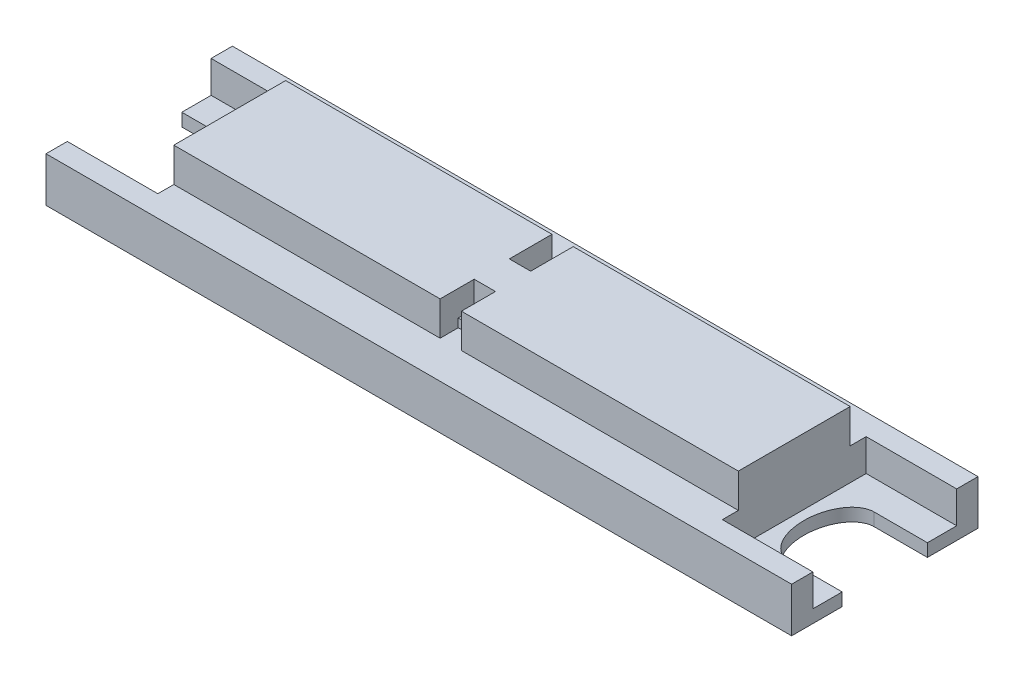
from build123d import *

# Parameters (mm, degrees)
CROQUIS1_W                   = 70
CROQUIS1_H                   = 17.5
SALIENTE_EXTRUIR1_DEPTH      = 4.2
CROQUIS2_W                   = 8.5
CROQUIS2_H                   = 13.5
CORTAR_EXTRUIR1_DEPTH        = 3
CORTAR_EXTRUIR2_DEPTH        = 2.2
SALIENTE_EXTRUIR2_DEPTH      = 3.2
CROQUIS5_R                   = 6.5
CORTAR_EXTRUIR3_DEPTH        = 4
CROQUIS6_W                   = 3.5
CROQUIS6_H                   = 6.5
CORTAR_EXTRUIR4_DEPTH        = 1
CROQUIS7_W                   = 14
CROQUIS7_H                   = 2
CORTAR_EXTRUIR5_DEPTH        = 1
CORTAR_EXTRUIR6_DEPTH        = 4
CROQUIS9_W                   = 3.489148649
CROQUIS9_H                   = 7.1
SALIENTE_EXTRUIR3_DEPTH      = 2
SALIENTE_EXTRUIR3_DEPTH_BACK = 1


with BuildPart() as part:
    # Croquis1 → Saliente-Extruir1 (new body)
    with BuildSketch(Plane(origin=(0, 0, 0), x_dir=(1, 0, 0), z_dir=(0, 1, 0))):
        with Locations((2.27027027, -4.304054054)):
            Rectangle(CROQUIS1_W, CROQUIS1_H)
    extrude(amount=SALIENTE_EXTRUIR1_DEPTH)

    # Croquis2 → Cortar-Extruir1 (cut)
    with BuildSketch(Plane(origin=(0, 4.2, 0), x_dir=(1, 0, 0), z_dir=(0, 1, 0))):
        with Locations((33.02027027, -4.304054054)):
            Rectangle(CROQUIS2_W, CROQUIS2_H)
        with Locations((-28.47972973, -4.304054054)):
            Rectangle(CROQUIS2_W, CROQUIS2_H)
    extrude(amount=-CORTAR_EXTRUIR1_DEPTH, mode=Mode.SUBTRACT)

    # Croquis3 → Cortar-Extruir2 (cut, through all)
    with BuildSketch(Plane(origin=(0, 1.2, 0), x_dir=(1, 0, 0), z_dir=(0, 1, 0))):
        with BuildLine():
            Line((37.27027027, -0.304054054), (32.27027027, -0.304054054))
            add(Edge.make_bspline(
                [(32.27027027, -0.304054054), (28.823561714, -0.304054054), (29.77027027, -5.402735351)],
                knots=[0, 0, 0, 1.84904315, 1.84904315, 1.84904315], degree=2, weights=[1, 0.602216604, 1]))
            add(Edge.make_bspline(
                [(29.77027027, -5.402735351), (30.308978827, -8.304054054), (32.27027027, -8.304054054)],
                knots=[4.990635803, 4.990635803, 4.990635803, 6.283185307, 6.283185307, 6.283185307], degree=2, weights=[1, 0.798332739, 1]))
            Line((32.27027027, -8.304054054), (37.27027027, -8.304054054))
            Line((37.27027027, -8.304054054), (37.27027027, -0.304054054))
        make_face()
        with BuildLine():
            Line((-32.72972973, -0.304054054), (-27.72972973, -0.304054054))
            add(Edge.make_bspline(
                [(-25.22972973, -4.304054054), (-25.22972973, -0.304054054), (-27.72972973, -0.304054054)],
                knots=[4.71238898, 4.71238898, 4.71238898, 6.283185307, 6.283185307, 6.283185307], degree=2, weights=[1, 0.707106781, 1]))
            add(Edge.make_bspline(
                [(-27.72972973, -8.304054054), (-25.22972973, -8.304054054), (-25.22972973, -4.304054054)],
                knots=[3.141592654, 3.141592654, 3.141592654, 4.71238898, 4.71238898, 4.71238898], degree=2, weights=[1, 0.707106781, 1]))
            Line((-27.72972973, -8.304054054), (-32.72972973, -8.304054054))
            Line((-32.72972973, -8.304054054), (-32.72972973, -0.304054054))
        make_face()
    extrude(amount=-CORTAR_EXTRUIR2_DEPTH, mode=Mode.SUBTRACT)

    # Croquis4 → Saliente-Extruir2 (add)
    with BuildSketch(Plane(origin=(0, 4.2, 0), x_dir=(1, 0, 0), z_dir=(0, 1, 0))):
        Polygon((-24.22972973, 0.945945946), (0.77027027, 0.945945946), (0.77027027, -3.054054054), (2.77027027, -3.054054054), (2.77027027, 0.945945946), (28.77027027, 0.945945946), (28.77027027, -9.554054054), (2.77027027, -9.554054054), (2.77027027, -6.354054054), (0.77027027, -6.354054054), (0.77027027, -9.554054054), (-24.22972973, -9.554054054), align=None)
    extrude(amount=SALIENTE_EXTRUIR2_DEPTH)

    # Croquis5 → Cortar-Extruir3 (cut)
    with BuildSketch(Plane.XZ):
        with Locations((-14.774068223, 3.554054054)):
            Circle(CROQUIS5_R)
        with Locations((19.216382303, 3.554054054)):
            Circle(CROQUIS5_R)
    extrude(amount=-CORTAR_EXTRUIR3_DEPTH, mode=Mode.SUBTRACT)

    # Croquis6 → Cortar-Extruir4 (cut)
    with BuildSketch(Plane.XZ.offset(-4)):
        with Locations((-17.324068223, 3.554054054)):
            Rectangle(CROQUIS6_W, CROQUIS6_H)
        with Locations((-12.224068223, 3.554054054)):
            Rectangle(CROQUIS6_W, CROQUIS6_H)
        with Locations((16.712940217, 3.293189119)):
            Rectangle(CROQUIS6_W, CROQUIS6_H)
        with Locations((21.812940217, 3.293189119)):
            Rectangle(CROQUIS6_W, CROQUIS6_H)
    extrude(amount=-CORTAR_EXTRUIR4_DEPTH, mode=Mode.SUBTRACT)

    # Croquis7 → Cortar-Extruir5 (cut)
    with BuildSketch(Plane.XZ):
        with Locations((1.291935528, -0.245945946)):
            Rectangle(CROQUIS7_W, CROQUIS7_H)
        with Locations((1.291935528, 8.854054054)):
            Rectangle(CROQUIS7_W, CROQUIS7_H)
    extrude(amount=-CORTAR_EXTRUIR5_DEPTH, mode=Mode.SUBTRACT)

    # Croquis8 → Cortar-Extruir6 (cut)
    with BuildSketch(Plane.XZ):
        with BuildLine():
            Line((-5.708064472, 7.854054054), (-5.708064472, 0.754054054))
            Line((-5.708064472, 0.754054054), (8.291935528, 0.754054054))
            Line((8.291935528, 0.754054054), (12.291935528, 0.754054054))
            add(Edge.make_bspline(
                [(11.291935528, 4.304054054), (11.291935528, 0.754054054), (12.291935528, 0.754054054)],
                knots=[1.570796327, 1.570796327, 1.570796327, 3.141592654, 3.141592654, 3.141592654], degree=2, weights=[1, 0.707106781, 1]))
            add(Edge.make_bspline(
                [(12.291935528, 7.854054054), (11.291935528, 7.854054054), (11.291935528, 4.304054054)],
                knots=[0, 0, 0, 1.570796327, 1.570796327, 1.570796327], degree=2, weights=[1, 0.707106781, 1]))
            Line((12.291935528, 7.854054054), (8.291935528, 7.854054054))
            Line((8.291935528, 7.854054054), (-5.708064472, 7.854054054))
        make_face()
    extrude(amount=-CORTAR_EXTRUIR6_DEPTH, mode=Mode.SUBTRACT)

    # Croquis9 → Saliente-Extruir3 (add, two sides)
    with BuildSketch(Plane.XZ.offset(-4)) as saliente_extruir3_sk:
        with Locations((-0.252638796, 4.304054054)):
            Rectangle(CROQUIS9_W, CROQUIS9_H)
    extrude(amount=SALIENTE_EXTRUIR3_DEPTH)
    extrude(saliente_extruir3_sk.sketch, amount=-SALIENTE_EXTRUIR3_DEPTH_BACK)


solid = part.part
